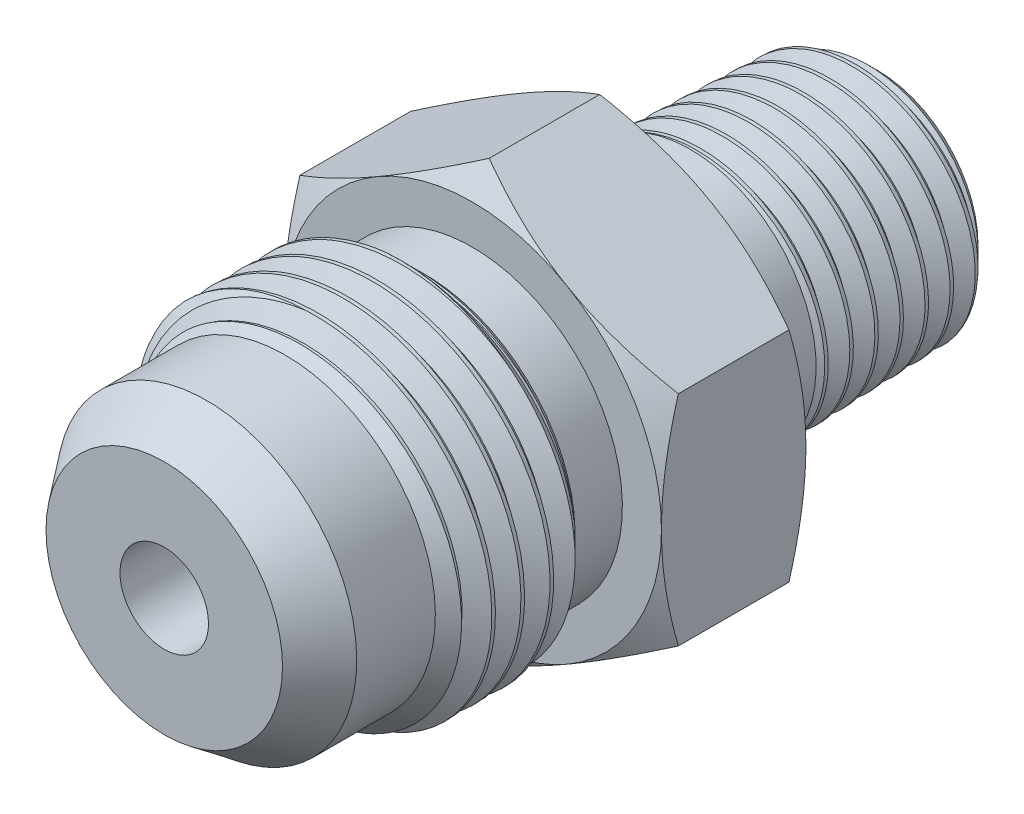
from build123d import *

# Parameters (mm, degrees)
SKETCH2_R               = 10.19175
BOSS_EXTRUDE1_DEPTH     = 7.874
SWEEP1_PITCH            = 1.5875
SWEEP1_HEIGHT           = 16.79575
SWEEP1_RADIUS           = 9.525
SWEEP1_START_ANGLE      = 90
SWEEP2_PITCH            = 1.411794907
SWEEP2_HEIGHT           = 11.616831111
SWEEP2_RADIUS           = 6.540243957
SWEEP2_START_ANGLE      = 90
SKETCH8_W               = 14.4719675
SKETCH8_H               = 23.83013236
CUT_EXTRUDE1_DEPTH      = 27.184778073
CUT_EXTRUDE1_DEPTH_BACK = 27.184778073


with BuildPart() as part:
    # Sketch1 → Revolve1 (revolve)
    with BuildSketch(Plane(origin=(0, 0, 0), x_dir=(0, 0, -1), z_dir=(1, 0, 0)), mode=Mode.PRIVATE) as revolve1_sk:
        Polygon((-19.446875, 2.413), (-19.446875, 6.448056668), (-17.138253125, 8.187728032), (-12.8508125, 8.187728032), (-11.513540532, 9.525), (-6.568084468, 9.525), (-5.2308125, 8.187728032), (-2.651125, 8.187728032), (-2.651125, 10.31875), (5.222875, 10.31875), (5.222875, 6.858), (9.241155, 6.858), (18.354531448, 6.574254175), (19.446875, 5.481910623), (19.446875, 2.413), align=None)
    revolve(revolve1_sk.sketch.rotate(Axis((0, 0, 19.446875), (0, 0, -1)), 180), axis=Axis((0, 0, 19.446875), (0, 0, -1)))

    # Sketch2 → Boss-Extrude1 (add)
    with BuildSketch(Plane.XY.offset(2.651125)):
        Polygon((0, 11.91506618), (-10.31875, 5.95753309), (-10.31875, -5.95753309), (0, -11.91506618), (10.31875, -5.95753309), (10.31875, 5.95753309), align=None)
        Circle(SKETCH2_R, mode=Mode.SUBTRACT)
    extrude(amount=-BOSS_EXTRUDE1_DEPTH)

    # Sketch3 → Cut-Revolve1 (revolve, cut)
    with BuildSketch(Plane(origin=(0, 0, 0), x_dir=(0, 0, -1), z_dir=(1, 0, 0))):
        Polygon((-2.651125, 10.31875), (-2.651125, 11.91506618), (-1.729491424, 11.91506618), align=None)
        Polygon((4.301241424, 11.91506618), (5.222875, 10.31875), (5.222875, 11.91506618), align=None)
    revolve(axis=Axis((0, 0, 19.446875), (0, 0, -1)), mode=Mode.SUBTRACT)


with BuildPart() as body_2:
    # Sweep1: sweep along a helix
    with BuildLine() as sweep1_path:
        add(Helix(SWEEP1_PITCH, SWEEP1_HEIGHT, SWEEP1_RADIUS, center=(0, 0, 19.446875), direction=(0, 0, -1), mode=Mode.PRIVATE).rotate(Axis((0, 0, 19.446875), (0, 0, -1)), SWEEP1_START_ANGLE))
    # Sketch5 → Sweep1 (sweep)
    with BuildSketch(Plane(origin=(0, 0, 0), x_dir=(0, 0, -1), z_dir=(1, 0, 0))):
        Polygon((-19.373551516, 9.652), (-20.0421875, 8.493888504), (-20.240625, 8.493888504), (-20.909260984, 9.652), align=None)
    sweep(path=sweep1_path.line, is_frenet=True)


with BuildPart() as body_3:
    # Sweep2: sweep along a helix
    with BuildLine() as sweep2_path:
        # a taper helix: rise per turn along the axis 1.411111111, along the cone's slant (build123d's pitch) 1.411794907
        add(Helix(SWEEP2_PITCH, SWEEP2_HEIGHT, SWEEP2_RADIUS, center=(0, 0, -19.446875), direction=(0, 0, 1), cone_angle=1.783333333, mode=Mode.PRIVATE).rotate(Axis((0, 0, -19.446875), (0, 0, 1)), SWEEP2_START_ANGLE))
    # Sketch7 → Sweep2 (sweep)
    with BuildSketch(Plane(origin=(0, 0, 0), x_dir=(0, 0, -1), z_dir=(1, 0, 0))):
        Polygon((19.373551516, 6.667243957), (19.976041667, 5.623700404), (20.152430556, 5.623700404), (20.754920706, 6.667243957), align=None)
    sweep(path=sweep2_path.line, is_frenet=True)


with BuildPart() as cut_extrude1_tool:
    # Sketch8 → Cut-Extrude1 (new, two sides)
    with BuildSketch(Plane(origin=(0, 0, 0), x_dir=(0, 0, -1), z_dir=(1, 0, 0))) as cut_extrude1_sk:
        with Locations((2.00517125, 0)):
            Rectangle(SKETCH8_W, SKETCH8_H)
    extrude(amount=CUT_EXTRUDE1_DEPTH)
    extrude(cut_extrude1_sk.sketch, amount=-CUT_EXTRUDE1_DEPTH_BACK)


with BuildPart() as body_2_1:
    add(body_2.part)

    # Cut-Extrude1: cut by cut_extrude1_tool
    add(cut_extrude1_tool.part, mode=Mode.SUBTRACT)


with BuildPart() as body_3_1:
    add(body_3.part)

    # Cut-Extrude1: cut by cut_extrude1_tool
    add(cut_extrude1_tool.part, mode=Mode.SUBTRACT)


with BuildPart() as part_1:
    add(part.part)

    # Combine1: cut body 2, body 3
    add(body_2_1.part, mode=Mode.SUBTRACT)
    add(body_3_1.part, mode=Mode.SUBTRACT)


solid = part_1.part
